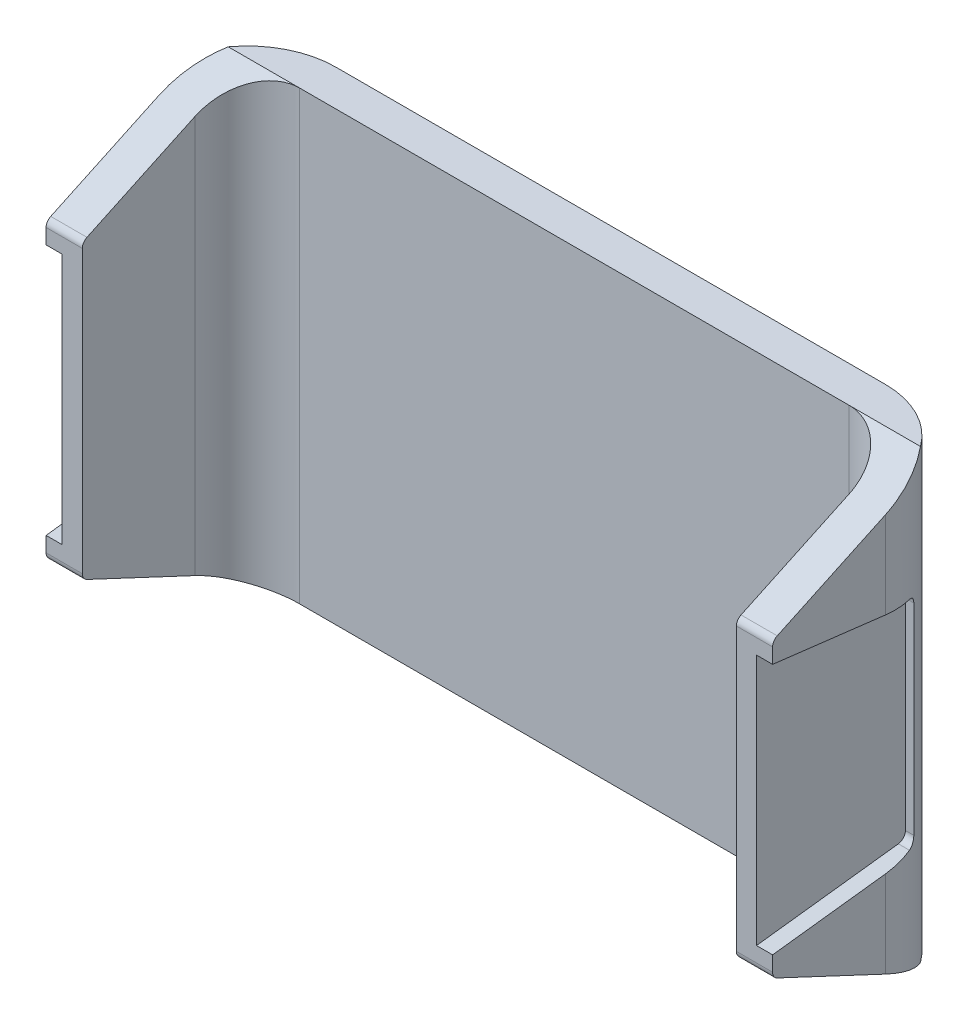
from build123d import *

# Parameters (mm, degrees)
BASE_EXTRUDE_THIN_DEPTH = 14.097
CUT_EXTRUDE1_DEPTH      = 46.847
CUT_EXTRUDE2_DEPTH      = 1.016
CUT_EXTRUDE3_DEPTH      = 1.016


with BuildPart() as part:
    # Sketch1 → Base-Extrude-Thin (new body, symmetric)
    with BuildSketch(Plane(origin=(0, 0, 0), x_dir=(1, 0, 0), z_dir=(0, 1, 0))):
        with BuildLine():
            Line((20.6375, 0), (20.6375, 7.112))
            ThreePointArc((20.6375, 7.112), (19.670366591, 9.446866591), (17.3355, 10.414))
            Line((17.3355, 10.414), (-17.3355, 10.414))
            ThreePointArc((-17.3355, 10.414), (-19.670366591, 9.446866591), (-20.6375, 7.112))
            Line((-20.6375, 7.112), (-20.6375, 0))
            Line((-20.6375, 0), (-22.9235, 0))
            Line((-22.9235, 0), (-22.9235, 7.112))
            ThreePointArc((-22.9235, 7.112), (-21.286812693, 11.063312693), (-17.3355, 12.7))
            Line((-17.3355, 12.7), (17.3355, 12.7))
            ThreePointArc((17.3355, 12.7), (21.286812693, 11.063312693), (22.9235, 7.112))
            Line((22.9235, 7.112), (22.9235, 0))
            Line((22.9235, 0), (20.6375, 0))
        make_face()
    extrude(amount=BASE_EXTRUDE_THIN_DEPTH, both=True)

    # Sketch2 → Cut-Extrude1 (cut, through all)
    with BuildSketch(Plane(origin=(22.9235, 0, 0), x_dir=(0, 0, -1), z_dir=(1, 0, 0))):
        with BuildLine():
            Line((73.891155103, 43.867726973), (10.414, 14.097))
            Line((10.414, 14.097), (0.292293676, 9.349929105))
            ThreePointArc((0.292293676, 9.349929105), (0.079256013, 9.162474941), (0, 8.89))
            Line((0, 8.89), (0, -8.89))
            ThreePointArc((0, -8.89), (0.079256013, -9.162474941), (0.292293676, -9.349929105))
            Line((0.292293676, -9.349929105), (10.414, -14.097))
            Line((10.414, -14.097), (73.891155103, -43.867726973))
            Line((73.891155103, -43.867726973), (-66.33217255, -43.867726973))
            Line((-66.33217255, -43.867726973), (-66.33217255, 43.867726973))
            Line((-66.33217255, 43.867726973), (73.891155103, 43.867726973))
        make_face()
    extrude(amount=-CUT_EXTRUDE1_DEPTH, mode=Mode.SUBTRACT)

    # Sketch4 → Cut-Extrude2 (cut)
    with BuildSketch(Plane(origin=(22.9235, 0, 0), x_dir=(0, 0, -1), z_dir=(1, 0, 0))):
        with BuildLine():
            Line((0, 7.9375), (8.951028719, 6.854320826))
            ThreePointArc((8.951028719, 6.854320826), (9.270175347, 6.686943178), (9.398, 6.35))
            Line((9.398, 6.35), (9.398, -6.35))
            ThreePointArc((9.398, -6.35), (9.270175347, -6.686943178), (8.951028719, -6.854320826))
            Line((8.951028719, -6.854320826), (0, -7.9375))
            Line((0, -7.9375), (0, 7.9375))
        make_face()
    extrude(amount=-CUT_EXTRUDE2_DEPTH, mode=Mode.SUBTRACT)

    # Sketch5 → Cut-Extrude3 (cut)
    with BuildSketch(Plane.ZY.offset(22.9235)):
        with BuildLine():
            Line((0, 7.9375), (0, -7.9375))
            Line((0, -7.9375), (-8.951028719, -6.854320826))
            ThreePointArc((-8.951028719, -6.854320826), (-9.270175347, -6.686943178), (-9.398, -6.35))
            Line((-9.398, -6.35), (-9.398, 6.35))
            ThreePointArc((-9.398, 6.35), (-9.270175347, 6.686943178), (-8.951028719, 6.854320826))
            Line((-8.951028719, 6.854320826), (0, 7.9375))
        make_face()
    extrude(amount=-CUT_EXTRUDE3_DEPTH, mode=Mode.SUBTRACT)


solid = part.part
